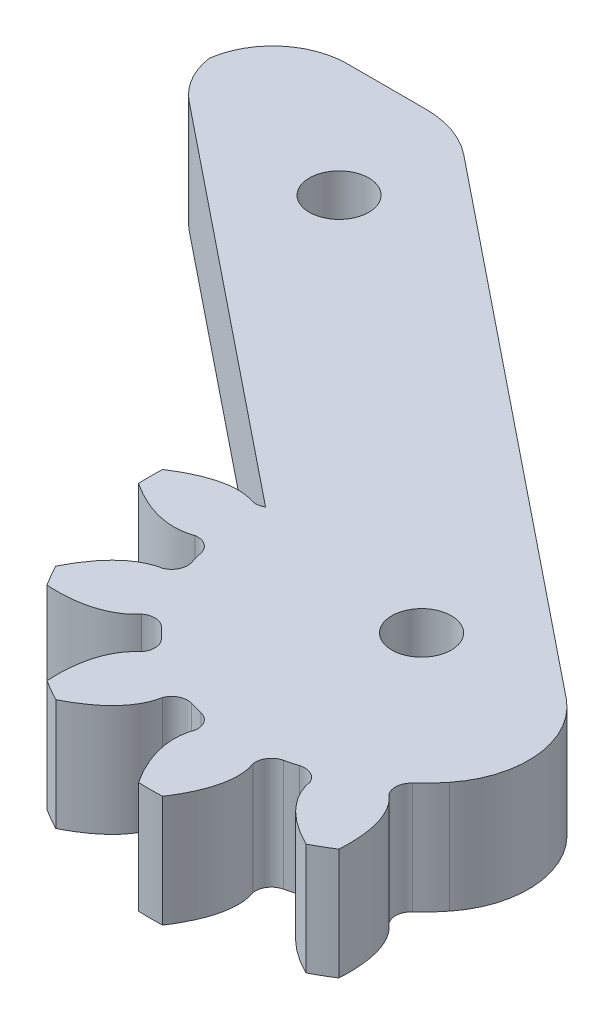
from build123d import *

# Parameters (mm, degrees)
RESSALTO_EXTRUS_O1_DEPTH = 6
CORTE_EXTRUS_O1_DEPTH    = 7.0000001
CORTE_EXTRUS_O2_DEPTH    = 7.0000001
CORTE_EXTRUS_O3_DEPTH    = 7.0000001
CORTE_EXTRUS_O4_DEPTH    = 7.0000001
ESBO_O6_R                = 1.6
CORTE_EXTRUS_O5_DEPTH    = 7.0000001
ESBO_O7_R                = 1.6
CORTE_EXTRUS_O6_DEPTH    = 7.0000001


with BuildPart() as part:
    # Esboço1 → Ressalto-extrusão1 (new body)
    with BuildSketch(Plane.XZ.offset(6)):
        with BuildLine():
            Line((-35.053391166, -1.665767354), (-56.005959689, -18.507024557))
            ThreePointArc((-56.005959689, -18.507024557), (-56.976417823, -19.646228266), (-57.460270003, -21.062371319))
            ThreePointArc((-57.460270003, -21.062371319), (-56.122071197, -23.520718894), (-53.5, -24.5))
            Line((-53.5, -24.5), (-49.26036734, -24.5))
            ThreePointArc((-49.26036734, -24.5), (-47.599906261, -24.216234622), (-46.127917729, -23.397147602))
            Line((-46.127917729, -23.397147602), (-18.051593362, -0.829957358))
            ThreePointArc((-18.051593362, -0.829957358), (-16.213367114, 2.526467109), (-17.286895371, 6.199639856))
            ThreePointArc((-17.286895371, 6.199639856), (-17.752824847, 6.738395184), (-18.256300836, 7.242239912))
            ThreePointArc((-18.256300836, 7.242239912), (-18.528297677, 7.80831066), (-18.343735303, 8.408606506))
            add(Edge.make_bspline(
                [(-18.343735303, 8.408606506), (-16.98173735, 9.54416389), (-17.156613946, 12.29450716)],
                knots=[0.078549619, 0.078549619, 0.078549619, 0.770539159, 0.770539159, 0.770539159], degree=2, weights=[1, 0.940738559, 1]))
            ThreePointArc((-17.156613946, 12.29450716), (-32.291666667, 12.629537139), (-39.569048555, -0.645317995))
            add(Edge.make_bspline(
                [(-39.569048555, -0.645317995), (-37.274619711, -2.171937204), (-35.610199193, -1.560191069)],
                knots=[2.371053495, 2.371053495, 2.371053495, 3.063043035, 3.063043035, 3.063043035], degree=2, weights=[1, 0.940738559, 1]))
            ThreePointArc((-35.610199193, -1.560191069), (-35.322864942, -1.565881251), (-35.053391166, -1.665767354))
        make_face()
    extrude(amount=-RESSALTO_EXTRUS_O1_DEPTH)

    # Esboço2 → Corte-extrusão1 (cut, through all)
    with BuildSketch(Plane(origin=(0, 0, 0), x_dir=(-1, 0, 0), z_dir=(0, 1, 0))):
        with BuildLine():
            ThreePointArc((24.354682005, 14.569048555), (21.225555592, 14.0864183), (18.274337499, 12.939825155))
            add(Edge.make_bspline(
                [(21.046065504, 9.968797575), (20.743642938, 11.716101094), (18.274337499, 12.939825155)],
                knots=[3.220142273, 3.220142273, 3.220142273, 3.912131812, 3.912131812, 3.912131812], degree=2, weights=[1, 0.940738559, 1]))
            ThreePointArc((21.046065504, 9.968797575), (21.47365577, 9.508813947), (22.099885838, 9.461334748))
            ThreePointArc((22.099885838, 9.461334748), (22.438769866, 9.558640989), (22.780905164, 9.643813326))
            ThreePointArc((22.780905164, 9.643813326), (23.299496712, 9.998046554), (23.439808931, 10.610199193))
            add(Edge.make_bspline(
                [(24.354682005, 14.569048555), (22.828062796, 12.274619711), (23.439808931, 10.610199193)],
                knots=[2.371053495, 2.371053495, 2.371053495, 3.063043035, 3.063043035, 3.063043035], degree=2, weights=[1, 0.940738559, 1]))
        make_face()
    extrude(amount=-CORTE_EXTRUS_O1_DEPTH, mode=Mode.SUBTRACT)

    # Esboço3 → Corte-extrusão2 (cut, through all)
    with BuildSketch(Plane(origin=(0, 0, 0), x_dir=(-1, 0, 0), z_dir=(0, 1, 0))):
        with BuildLine():
            ThreePointArc((31.725662501, 12.939825155), (28.774444408, 14.0864183), (25.645317995, 14.569048555))
            add(Edge.make_bspline(
                [(26.560191069, 10.610199193), (27.171937204, 12.274619711), (25.645317995, 14.569048555)],
                knots=[3.220142273, 3.220142273, 3.220142273, 3.912131812, 3.912131812, 3.912131812], degree=2, weights=[1, 0.940738559, 1]))
            ThreePointArc((26.560191069, 10.610199193), (26.700503288, 9.998046554), (27.219094836, 9.643813326))
            ThreePointArc((27.219094836, 9.643813326), (27.561230134, 9.558640989), (27.900114162, 9.461334748))
            ThreePointArc((27.900114162, 9.461334748), (28.52634423, 9.508813947), (28.953934496, 9.968797575))
            add(Edge.make_bspline(
                [(31.725662501, 12.939825155), (29.256357062, 11.716101094), (28.953934496, 9.968797575)],
                knots=[2.371053495, 2.371053495, 2.371053495, 3.063043035, 3.063043035, 3.063043035], degree=2, weights=[1, 0.940738559, 1]))
        make_face()
    extrude(amount=-CORTE_EXTRUS_O2_DEPTH, mode=Mode.SUBTRACT)

    # Esboço4 → Corte-extrusão3 (cut, through all)
    with BuildSketch(Plane(origin=(0, 0, 0), x_dir=(-1, 0, 0), z_dir=(0, 1, 0))):
        with BuildLine():
            ThreePointArc((37.29450716, 7.843386054), (35.311973892, 10.311973892), (32.843386054, 12.29450716))
            add(Edge.make_bspline(
                [(31.656264697, 8.408606506), (33.01826265, 9.54416389), (32.843386054, 12.29450716)],
                knots=[3.220142273, 3.220142273, 3.220142273, 3.912131812, 3.912131812, 3.912131812], degree=2, weights=[1, 0.940738559, 1]))
            ThreePointArc((31.656264697, 8.408606506), (31.471702323, 7.80831066), (31.743699164, 7.242239912))
            ThreePointArc((31.743699164, 7.242239912), (31.997410855, 6.997410855), (32.242239912, 6.743699164))
            ThreePointArc((32.242239912, 6.743699164), (32.80831066, 6.471702323), (33.408606506, 6.656264697))
            add(Edge.make_bspline(
                [(37.29450716, 7.843386054), (34.54416389, 8.01826265), (33.408606506, 6.656264697)],
                knots=[5.512646149, 5.512646149, 5.512646149, 6.204635688, 6.204635688, 6.204635688], degree=2, weights=[1, 0.940738559, 1]))
        make_face()
    extrude(amount=-CORTE_EXTRUS_O3_DEPTH, mode=Mode.SUBTRACT)

    # Esboço5 → Corte-extrusão4 (cut, through all)
    with BuildSketch(Plane(origin=(0, 0, 0), x_dir=(-1, 0, 0), z_dir=(0, 1, 0))):
        with BuildLine():
            ThreePointArc((39.569048555, 0.645317995), (39.0864183, 3.774444408), (37.939825155, 6.725662501))
            add(Edge.make_bspline(
                [(34.968797575, 3.953934496), (36.716101094, 4.256357062), (37.939825155, 6.725662501)],
                knots=[3.220142273, 3.220142273, 3.220142273, 3.912131812, 3.912131812, 3.912131812], degree=2, weights=[1, 0.940738559, 1]))
            ThreePointArc((34.968797575, 3.953934496), (34.508813947, 3.52634423), (34.461334748, 2.900114162))
            ThreePointArc((34.461334748, 2.900114162), (34.558640989, 2.561230134), (34.643813326, 2.219094836))
            ThreePointArc((34.643813326, 2.219094836), (34.998046554, 1.700503288), (35.610199193, 1.560191069))
            add(Edge.make_bspline(
                [(39.569048555, 0.645317995), (37.274619711, 2.171937204), (35.610199193, 1.560191069)],
                knots=[2.371053495, 2.371053495, 2.371053495, 3.063043035, 3.063043035, 3.063043035], degree=2, weights=[1, 0.940738559, 1]))
        make_face()
    extrude(amount=-CORTE_EXTRUS_O4_DEPTH, mode=Mode.SUBTRACT)

    # Esboço6 → Corte-extrusão5 (cut, through all)
    with BuildSketch(Plane.XZ.offset(6)):
        with Locations((-25, 0)):
            Circle(ESBO_O6_R)
    extrude(amount=-CORTE_EXTRUS_O5_DEPTH, mode=Mode.SUBTRACT)

    # Esboço7 → Corte-extrusão6 (cut, through all)
    with BuildSketch(Plane(origin=(0, 0, 0), x_dir=(-1, 0, 0), z_dir=(0, 1, 0))):
        with Locations((47.598401843, -18.16414524)):
            Circle(ESBO_O7_R)
    extrude(amount=-CORTE_EXTRUS_O6_DEPTH, mode=Mode.SUBTRACT)


solid = part.part
